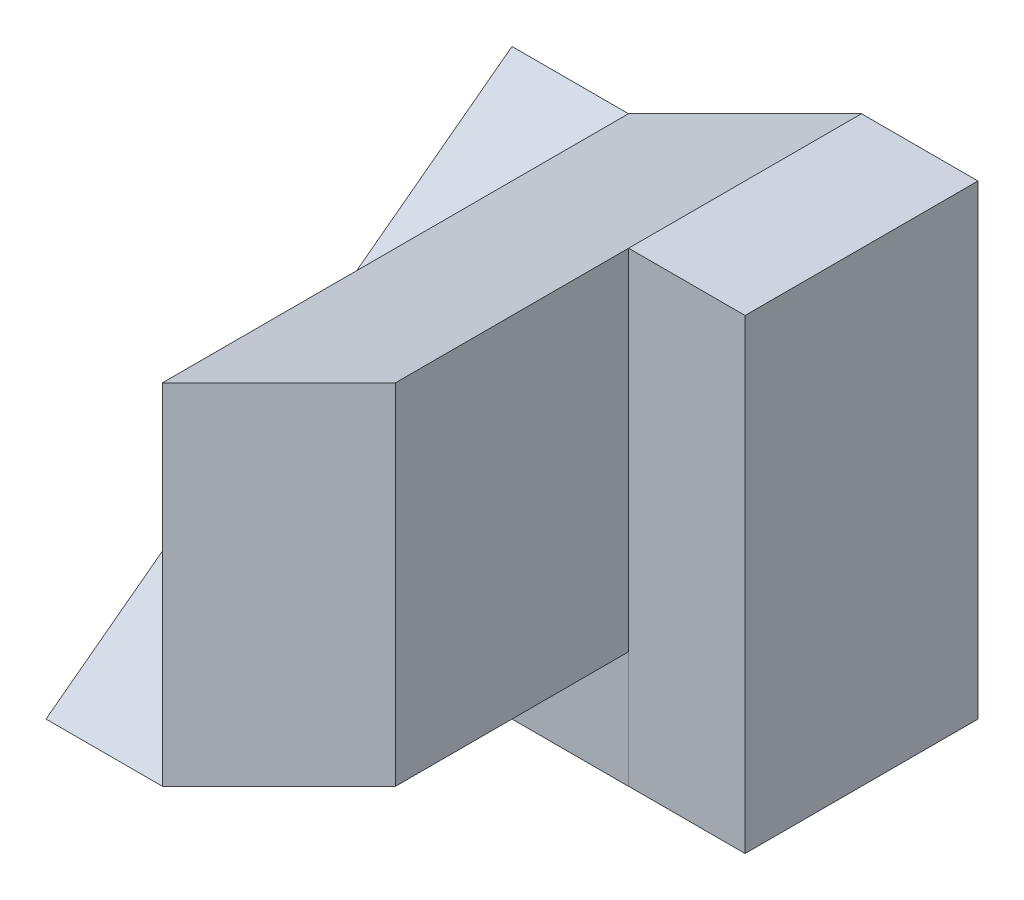
from build123d import *

# Parameters (mm, degrees)
BOSS_EXTRUDE1_DEPTH = 1
SKETCH3_W           = 4
SKETCH3_H           = 4
BOSS_EXTRUDE2_DEPTH = 2
CUT_EXTRUDE1_DEPTH  = 2
CUT_EXTRUDE2_DEPTH  = 2
SKETCH7_W           = 1.99922299
SKETCH7_H           = 4
BOSS_EXTRUDE3_DEPTH = 1


with BuildPart() as part:
    # Sketch2 → Boss-Extrude1 (new body)
    with BuildSketch(Plane(origin=(0, 0, 0), x_dir=(0, 0, -1), z_dir=(1, 0, 0))):
        Polygon((0, 0), (0, 3), (-4, 0), align=None)
    extrude(amount=BOSS_EXTRUDE1_DEPTH)

    # Sketch3 → Boss-Extrude2 (add)
    with BuildSketch(Plane(origin=(1, 0, 0), x_dir=(0, 0, -1), z_dir=(1, 0, 0))):
        with Locations((-2, 2)):
            Rectangle(SKETCH3_W, SKETCH3_H)
    extrude(amount=BOSS_EXTRUDE2_DEPTH)

    # Sketch5 → Cut-Extrude1 (cut)
    with BuildSketch(Plane.XY.offset(4)):
        Polygon((3, 4), (1, 3), (1, 4), align=None)
        Polygon((1, 0), (3, 1), (3, 0), align=None)
    extrude(amount=-CUT_EXTRUDE1_DEPTH, mode=Mode.SUBTRACT)

    # Sketch6 → Cut-Extrude2 (cut)
    with BuildSketch(Plane.XY.offset(2)):
        Polygon((3, 4), (1, 4), (1, 3), align=None)
    extrude(amount=-CUT_EXTRUDE2_DEPTH, mode=Mode.SUBTRACT)

    # Sketch7 → Boss-Extrude3 (add)
    with BuildSketch(Plane(origin=(3, 0, 0), x_dir=(0, 0, -1), z_dir=(1, 0, 0))):
        with Locations((-0.999611495, 2)):
            Rectangle(SKETCH7_W, SKETCH7_H)
    extrude(amount=BOSS_EXTRUDE3_DEPTH)


solid = part.part
